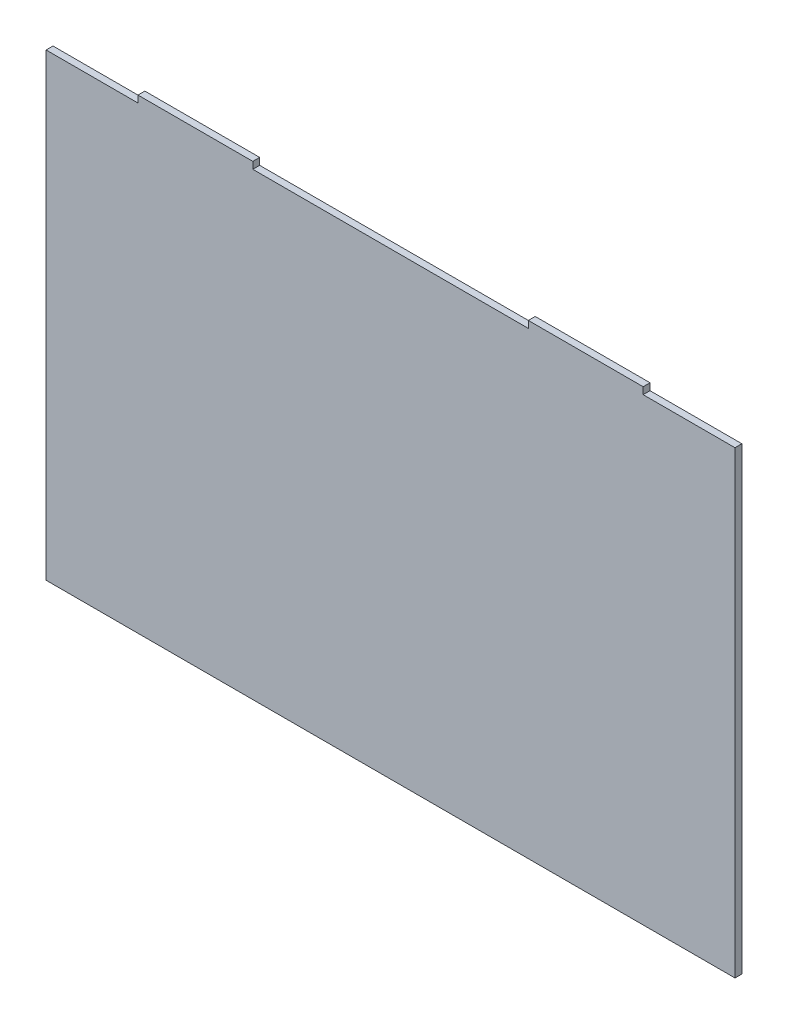
from build123d import *

# Parameters (mm, degrees)
ESQUISSE1_W             = 300
ESQUISSE1_H             = 203
BOSS_EXTRU_1_DEPTH      = 3
ESQUISSE2_W             = 40
ESQUISSE2_H             = 3
ESQUISSE2_W_2           = 120
ENL_V_MAT_EXTRU_1_DEPTH = 3


with BuildPart() as part:
    # Esquisse1 → Boss.-Extru.1 (new body)
    with BuildSketch(Plane.XY):
        Rectangle(ESQUISSE1_W, ESQUISSE1_H)
    extrude(amount=BOSS_EXTRU_1_DEPTH)

    # Esquisse2 → Enlèv. mat.-Extru.1 (cut)
    with BuildSketch(Plane.XY.offset(3)):
        with Locations((-130, 100)):
            Rectangle(ESQUISSE2_W, ESQUISSE2_H)
        with Locations((0, 100)):
            Rectangle(ESQUISSE2_W_2, ESQUISSE2_H)
        with Locations((130, 100)):
            Rectangle(ESQUISSE2_W, ESQUISSE2_H)
    extrude(amount=-ENL_V_MAT_EXTRU_1_DEPTH, mode=Mode.SUBTRACT)


solid = part.part
